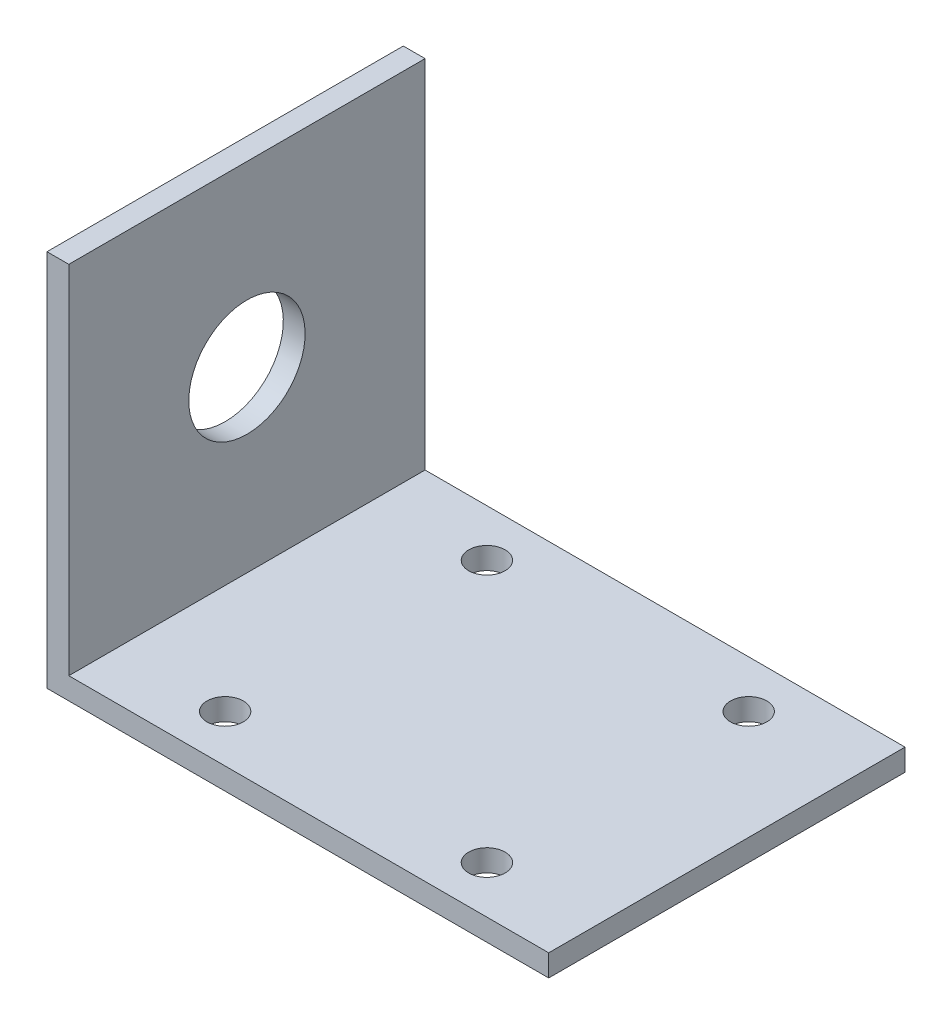
from build123d import *

# Parameters (mm, degrees)
EXTRUDE_1_DEPTH     = 49
SKETCH_2_R          = 2.5
CUT_EXTRUDE_1_DEPTH = 49
SKETCH_3_R          = 8
CUT_EXTRUDE_2_DEPTH = 49


with BuildPart() as part:
    # 草图1 → 凸台-拉伸1 (new body)
    with BuildSketch(Plane.XY):
        Polygon((-22.564432673, 30.231958763), (-22.564432673, -21.768041237), (46.435567327, -21.768041237), (46.435567327, -18.768041237), (-19.564432673, -18.768041237), (-19.564432673, 30.231958763), align=None)
    extrude(amount=EXTRUDE_1_DEPTH)

    # 草图2 → 切除-拉伸1 (cut)
    with BuildSketch(Plane(origin=(0, -18.768041237, 0), x_dir=(1, 0, 0), z_dir=(0, 1, 0))):
        with Locations((-4.564432673, -6.5)):
            Circle(SKETCH_2_R)
        with Locations((31.435567327, -6.5)):
            Circle(SKETCH_2_R)
        with Locations((-4.564432673, -42.5)):
            Circle(SKETCH_2_R)
        with Locations((31.435567327, -42.5)):
            Circle(SKETCH_2_R)
    extrude(amount=-CUT_EXTRUDE_1_DEPTH, mode=Mode.SUBTRACT)

    # 草图3 → 切除-拉伸2 (cut)
    with BuildSketch(Plane.ZY.offset(22.564432673)):
        with Locations((24.5, 5.731958763)):
            Circle(SKETCH_3_R)
    extrude(amount=-CUT_EXTRUDE_2_DEPTH, mode=Mode.SUBTRACT)


solid = part.part
